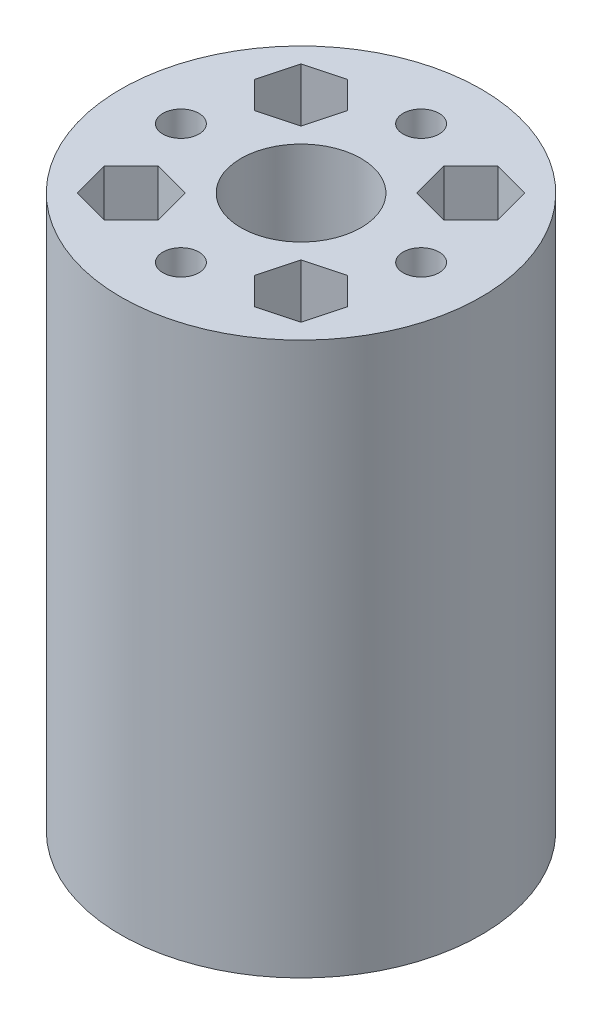
from build123d import *

# Parameters (mm, degrees)
SKETCH_1_R               = 15
SKETCH_1_R_2             = 5
EXTRUDE_4_DEPTH          = 3
SKETCH_1_R_3             = 3.5
SKETCH_1_R_4             = 2.1
EXTRUDE_4_2_DEPTH        = 3
EXTRUDE_5_DEPTH          = 3
PATTERN_CIRCULAR_2_COUNT = 4
SKETCH_6_R               = 3.5
SKETCH_6_R_2             = 2.1
EXTRUDE_6_DEPTH          = 3
PATTERN_CIRCULAR_3_COUNT = 4
SKETCH_7_R               = 15
SKETCH_7_R_2             = 5
EXTRUDE_7_DEPTH          = 46
CUT_EXTRUDE_1_DEPTH      = 46
PATTERN_CIRCULAR_4_COUNT = 4
SKETCH_11_R              = 1.5
CUT_EXTRUDE_2_DEPTH      = 3
PATTERN_CIRCULAR_5_COUNT = 4
EXTRUDE_8_DEPTH          = 3
EXTRUDE_9_DEPTH          = 3
EXTRUDE_10_DEPTH         = 3
EXTRUDE_11_DEPTH         = 3
EXTRUDE_13_DEPTH         = 3
EXTRUDE_14_DEPTH         = 3
CUT_EXTRUDE_3_DEPTH      = 2.5
SKETCH_19_R              = 1.5
CUT_EXTRUDE_4_DEPTH      = 2.5
SKETCH_20_R              = 1.5
CUT_EXTRUDE_5_DEPTH      = 2.5
SKETCH_21_R              = 15
SKETCH_21_R_2            = 5
EXTRUDE_15_DEPTH         = 3
SKETCH_22_R              = 1.5
CUT_EXTRUDE_6_DEPTH      = 3
PATTERN_CIRCULAR_6_COUNT = 4
EXTRUDE_16_DEPTH         = 3
CUT_EXTRUDE_7_DEPTH      = 3
SKETCH_25_R              = 15
SKETCH_25_R_2            = 5
EXTRUDE_17_DEPTH         = 43
SKETCH_27_R              = 1.5
CUT_EXTRUDE_8_DEPTH      = 46
SKETCH_28_R              = 2.75
CUT_EXTRUDE_9_DEPTH      = 43
SKETCH_29_R              = 1.5
CUT_EXTRUDE_10_DEPTH     = 46
PATTERN_CIRCULAR_7_COUNT = 4
CUT_EXTRUDE_11_DEPTH     = 43
PATTERN_CIRCULAR_8_COUNT = 4
SKETCH_31_R              = 43.855676254
CUT_EXTRUDE_12_DEPTH     = 100


with BuildPart() as part:
    # 草图1 → 凸台-拉伸4 (new body)
    with BuildSketch(Plane(origin=(0, 0, 0), x_dir=(1, 0, 0), z_dir=(0, 1, 0))):
        with Locations((-5.372895461, -8.931727747)):
            Circle(SKETCH_1_R)
        with Locations((-5.372895461, -8.931727747)):
            Circle(SKETCH_1_R_2, mode=Mode.SUBTRACT)
    extrude(amount=EXTRUDE_4_DEPTH)



with BuildPart() as body_2:
    # 草图1 → Extrude 4 2 (new body)
    with BuildSketch(Plane(origin=(0, 0, 0), x_dir=(1, 0, 0), z_dir=(0, 1, 0))):
        with Locations((-22.372895461, 8.068272253)):
            Circle(SKETCH_1_R_3)
        with Locations((-22.372895461, 8.068272253)):
            Circle(SKETCH_1_R_4, mode=Mode.SUBTRACT)
    extrude(amount=EXTRUDE_4_2_DEPTH)


with BuildPart() as part_1:
    add(part.part)

    add(body_2.part)  # 凸台-拉伸5 merges body 2
    # 草图5 → 凸台-拉伸5 (add)
    with BuildSketch(Plane(origin=(0, 0, 0), x_dir=(1, 0, 0), z_dir=(0, 1, 0))):
        Polygon((-22.372895461, 4.568272253), (-10.372895461, -8.931727747), (-10.372895461, -3.931727747), (-5.372895461, -3.931727747), (-18.872895461, 8.068272253), align=None)
    extrude_5 = extrude(amount=EXTRUDE_5_DEPTH)

    # 阵列(圆周)2: 凸台-拉伸5 ×4 about axis
    pattern_circular_2_axis = Axis((-5.372895461, 0, 8.931727747), (0, 1, 0))
    for i in range(1, PATTERN_CIRCULAR_2_COUNT):
        add(extrude_5.rotate(pattern_circular_2_axis, i * 360 / PATTERN_CIRCULAR_2_COUNT))

    # 草图6 → 凸台-拉伸6 (add)
    with BuildSketch(Plane(origin=(0, 3, 0), x_dir=(1, 0, 0), z_dir=(0, 1, 0))):
        with Locations((11.627104539, 8.068272253)):
            Circle(SKETCH_6_R)
        with Locations((11.627104539, 8.068272253)):
            Circle(SKETCH_6_R_2, mode=Mode.SUBTRACT)
    extrude_6 = extrude(amount=-EXTRUDE_6_DEPTH)

    # 阵列(圆周)3: 凸台-拉伸6 ×4 about axis
    pattern_circular_3_axis = Axis((-5.372895461, 0, 8.931727747), (0, 1, 0))
    for i in range(1, PATTERN_CIRCULAR_3_COUNT):
        add(extrude_6.rotate(pattern_circular_3_axis, i * 360 / PATTERN_CIRCULAR_3_COUNT))

    # 草图7 → 凸台-拉伸7 (add)
    with BuildSketch(Plane.XZ):
        with Locations((-5.372895461, 8.931727747)):
            Circle(SKETCH_7_R)
        with Locations((-5.372895461, 8.931727747)):
            Circle(SKETCH_7_R_2, mode=Mode.SUBTRACT)
    extrude(amount=EXTRUDE_7_DEPTH)

    # 草图9 → 切除-拉伸1 (cut)
    with BuildSketch(Plane(origin=(0, 3, 0), x_dir=(1, 0, 0), z_dir=(0, 1, 0))):
        Polygon((0.876311502, -19.070022006), (-1.369054096, -16.824656408), (-0.547193246, -13.757429961), (2.520033201, -12.935569112), (4.765398798, -15.180934709), (3.943537949, -18.248161156), align=None)
    cut_extrude_1 = extrude(amount=-CUT_EXTRUDE_1_DEPTH, mode=Mode.SUBTRACT)

    # 阵列(圆周)4: 切除-拉伸1 ×4 about axis
    pattern_circular_4_axis = Axis((-5.372895461, 0, 8.931727747), (0, 1, 0))
    for i in range(1, PATTERN_CIRCULAR_4_COUNT):
        add(cut_extrude_1.rotate(pattern_circular_4_axis, i * 360 / PATTERN_CIRCULAR_4_COUNT), mode=Mode.SUBTRACT)

    # 草图11 → 切除-拉伸2 (cut)
    with BuildSketch(Plane(origin=(0, -43, 0), x_dir=(1, 0, 0), z_dir=(0, 1, 0))):
        with Locations((1.698172351, -1.860659935)):
            Circle(SKETCH_11_R)
    cut_extrude_2 = extrude(amount=-CUT_EXTRUDE_2_DEPTH, mode=Mode.SUBTRACT)

    # 阵列(圆周)5: 切除-拉伸2 ×4 about axis
    pattern_circular_5_axis = Axis((-5.372895461, 0, 8.931727747), (0, 1, 0))
    for i in range(1, PATTERN_CIRCULAR_5_COUNT):
        add(cut_extrude_2.rotate(pattern_circular_5_axis, i * 360 / PATTERN_CIRCULAR_5_COUNT), mode=Mode.SUBTRACT)

    # 草图12 → 凸台-拉伸8 (add)
    with BuildSketch(Plane(origin=(0, 3, 0), x_dir=(1, 0, 0), z_dir=(0, 1, 0))):
        Polygon((15.127104539, 8.068272253), (15.127104539, -25.931727747), (11.627104539, -22.431727747), (11.627104539, 4.568272253), align=None)
    extrude(amount=-EXTRUDE_8_DEPTH)

    # 草图13 → 凸台-拉伸9 (add)
    with BuildSketch(Plane(origin=(0, 3, 0), x_dir=(1, 0, 0), z_dir=(0, 1, 0))):
        Polygon((11.627104539, 11.568272253), (-22.372895461, 11.568272253), (-18.872895461, 8.068272253), (8.127104539, 8.068272253), align=None)
    extrude(amount=-EXTRUDE_9_DEPTH)

    # 草图14 → 凸台-拉伸10 (add)
    with BuildSketch(Plane(origin=(0, 3, 0), x_dir=(1, 0, 0), z_dir=(0, 1, 0))):
        Polygon((-25.872895461, 8.068272253), (-25.872895461, -25.931727747), (-22.372895461, -22.431727747), (-22.372895461, 4.568272253), align=None)
    extrude(amount=-EXTRUDE_10_DEPTH)

    # 草图15 → 凸台-拉伸11 (add)
    with BuildSketch(Plane(origin=(0, 3, 0), x_dir=(1, 0, 0), z_dir=(0, 1, 0))):
        Polygon((-22.372895461, -29.431727747), (11.627104539, -29.431727747), (8.127104539, -25.931727747), (-18.872895461, -25.931727747), align=None)
    extrude(amount=-EXTRUDE_11_DEPTH)

    # 草图16 → 凸台-拉伸13 (add)
    with BuildSketch(Plane.XZ):
        Polygon((-10.747895461, -4.193272253), (0.002104539, -4.193272253), (5.163560245, -8.068272253), (4.99115505, -11.568272253), (0.002104539, -14.943272253), (-10.747895461, -14.943272253), (-15.736945971, -11.568272253), (-15.909351166, -8.068272253), align=None)
        Polygon((-7.57246898, -9.568272253), (-9.16018222, -6.818272253), (-12.335608701, -6.818272253), (-13.923321941, -9.568272253), (-12.335608701, -12.318272253), (-9.16018222, -12.318272253), align=None, mode=Mode.SUBTRACT)
        Polygon((3.17753102, -9.568272253), (1.58981778, -6.818272253), (-1.585608701, -6.818272253), (-3.173321941, -9.568272253), (-1.585608701, -12.318272253), (1.58981778, -12.318272253), align=None, mode=Mode.SUBTRACT)
    extrude(amount=-EXTRUDE_13_DEPTH)

    # 草图18 → 凸台-拉伸14 (add)
    with BuildSketch(Plane.XZ):
        Polygon((-7.57246898, -9.568272253), (-9.16018222, -6.818272253), (-12.335608701, -6.818272253), (-13.923321941, -9.568272253), (-12.335608701, -12.318272253), (-9.16018222, -12.318272253), align=None)
        Polygon((3.17753102, -9.568272253), (1.58981778, -6.818272253), (-1.585608701, -6.818272253), (-3.173321941, -9.568272253), (-1.585608701, -12.318272253), (1.58981778, -12.318272253), align=None)
    extrude(amount=-EXTRUDE_14_DEPTH)

    # 草图17 → 切除-拉伸3 (cut)
    with BuildSketch(Plane.XZ):
        Polygon((-7.57246898, -9.568272253), (-9.16018222, -6.818272253), (-12.335608701, -6.818272253), (-13.923321941, -9.568272253), (-12.335608701, -12.318272253), (-9.16018222, -12.318272253), align=None)
        Polygon((3.17753102, -9.568272253), (1.58981778, -6.818272253), (-1.585608701, -6.818272253), (-3.173321941, -9.568272253), (-1.585608701, -12.318272253), (1.58981778, -12.318272253), align=None)
    extrude(amount=-CUT_EXTRUDE_3_DEPTH, mode=Mode.SUBTRACT)

    # 草图19 → 切除-拉伸4 (cut)
    with BuildSketch(Plane.XZ.offset(-2.5)):
        with Locations((0.002104539, -9.568272253)):
            Circle(SKETCH_19_R)
    extrude(amount=-CUT_EXTRUDE_4_DEPTH, mode=Mode.SUBTRACT)

    # 草图20 → 切除-拉伸5 (cut)
    with BuildSketch(Plane.XZ.offset(-2.5)):
        with Locations((-10.747895461, -9.568272253)):
            Circle(SKETCH_20_R)
    extrude(amount=-CUT_EXTRUDE_5_DEPTH, mode=Mode.SUBTRACT)

    # 草图8 → 凸台-拉伸16 (add)
    with BuildSketch(Plane.XZ.offset(46)):
        Polygon((3.943537949, 18.248161156), (0.876311502, 19.070022006), (-1.369054096, 16.824656408), (-0.547193246, 13.757429961), (2.520033201, 12.935569112), (4.765398798, 15.180934709), align=None)
    extrude(amount=EXTRUDE_16_DEPTH)

    # 草图24 → 切除-拉伸7 (cut)
    with BuildSketch(Plane.XZ.offset(49)):
        Polygon((4.765398798, 15.180934709), (3.943537949, 18.248161156), (0.876311502, 19.070022006), (-1.369054096, 16.824656408), (-0.547193246, 13.757429961), (2.520033201, 12.935569112), align=None)
    extrude(amount=-CUT_EXTRUDE_7_DEPTH, mode=Mode.SUBTRACT)

    # 草图31 → 切除-拉伸12 (cut)
    with BuildSketch(Plane(origin=(0, 3, 0), x_dir=(1, 0, 0), z_dir=(0, 1, 0))):
        with Locations((-6.865297473, -8.372369535)):
            Circle(SKETCH_31_R)
    extrude(amount=-CUT_EXTRUDE_12_DEPTH, mode=Mode.SUBTRACT)


with BuildPart() as body_2_2:
    # 草图21 → 凸台-拉伸15 (new body)
    with BuildSketch(Plane(origin=(0, 0, 0), x_dir=(1, 0, 0), z_dir=(0, 1, 0))):
        with Locations((59.665545214, -8.931727747)):
            Circle(SKETCH_21_R)
        with Locations((59.665545214, -8.931727747)):
            Circle(SKETCH_21_R_2, mode=Mode.SUBTRACT)
    extrude(amount=EXTRUDE_15_DEPTH)

    # 草图22 → 切除-拉伸6 (cut)
    with BuildSketch(Plane.XZ):
        with Locations((59.665545214, 18.931727747)):
            Circle(SKETCH_22_R)
    cut_extrude_6 = extrude(amount=-CUT_EXTRUDE_6_DEPTH, mode=Mode.SUBTRACT)

    # 阵列(圆周)6: 切除-拉伸6 ×4 about axis
    pattern_circular_6_axis = Axis((59.665545214, 0, 8.931727747), (0, 1, 0))
    for i in range(1, PATTERN_CIRCULAR_6_COUNT):
        add(cut_extrude_6.rotate(pattern_circular_6_axis, i * 360 / PATTERN_CIRCULAR_6_COUNT), mode=Mode.SUBTRACT)

    # 草图25 → 凸台-拉伸17 (add)
    with BuildSketch(Plane.XZ):
        with Locations((59.665545214, 8.931727747)):
            Circle(SKETCH_25_R)
        with Locations((59.665545214, 8.931727747)):
            Circle(SKETCH_25_R_2, mode=Mode.SUBTRACT)
    extrude(amount=EXTRUDE_17_DEPTH)

    # 草图27 → 切除-拉伸8 (cut)
    with BuildSketch(Plane(origin=(0, 3, 0), x_dir=(1, 0, 0), z_dir=(0, 1, 0))):
        with Locations((59.665545214, 1.068272253)):
            Circle(SKETCH_27_R)
        with Locations((69.665545214, -8.931727747)):
            Circle(SKETCH_27_R)
        with Locations((59.665545214, -18.931727747)):
            Circle(SKETCH_27_R)
        with Locations((49.665545214, -8.931727747)):
            Circle(SKETCH_27_R)
    extrude(amount=-CUT_EXTRUDE_8_DEPTH, mode=Mode.SUBTRACT)

    # 草图28 → 切除-拉伸9 (cut)
    with BuildSketch(Plane.XZ.offset(43)):
        with Locations((59.665545214, 18.931727747)):
            Circle(SKETCH_28_R)
        with Locations((49.665545214, 8.931727747)):
            Circle(SKETCH_28_R)
        with Locations((59.665545214, -1.068272253)):
            Circle(SKETCH_28_R)
        with Locations((69.665545214, 8.931727747)):
            Circle(SKETCH_28_R)
    extrude(amount=-CUT_EXTRUDE_9_DEPTH, mode=Mode.SUBTRACT)

    # 草图29 → 切除-拉伸10 (cut)
    with BuildSketch(Plane(origin=(0, 3, 0), x_dir=(1, 0, 0), z_dir=(0, 1, 0))):
        with Locations((66.736613026, -1.860659935)):
            Circle(SKETCH_29_R)
    cut_extrude_10 = extrude(amount=-CUT_EXTRUDE_10_DEPTH, mode=Mode.SUBTRACT)

    # 阵列(圆周)7: 切除-拉伸10 ×4 about axis
    pattern_circular_7_axis = Axis((59.665545214, 0, 8.931727747), (0, 1, 0))
    for i in range(1, PATTERN_CIRCULAR_7_COUNT):
        add(cut_extrude_10.rotate(pattern_circular_7_axis, i * 360 / PATTERN_CIRCULAR_7_COUNT), mode=Mode.SUBTRACT)

    # 草图30 → 切除-拉伸11 (cut)
    with BuildSketch(Plane(origin=(0, 3, 0), x_dir=(1, 0, 0), z_dir=(0, 1, 0))):
        Polygon((64.491247429, -4.106025533), (67.558473876, -4.927886382), (69.803839473, -2.682520785), (68.981978624, 0.384705662), (65.914752177, 1.206566512), (63.669386579, -1.038799086), align=None)
    cut_extrude_11 = extrude(amount=-CUT_EXTRUDE_11_DEPTH, mode=Mode.SUBTRACT)

    # 阵列(圆周)8: 切除-拉伸11 ×4 about axis
    pattern_circular_8_axis = Axis((59.665545214, 0, 8.931727747), (0, 1, 0))
    for i in range(1, PATTERN_CIRCULAR_8_COUNT):
        add(cut_extrude_11.rotate(pattern_circular_8_axis, i * 360 / PATTERN_CIRCULAR_8_COUNT), mode=Mode.SUBTRACT)


solid = body_2_2.part
